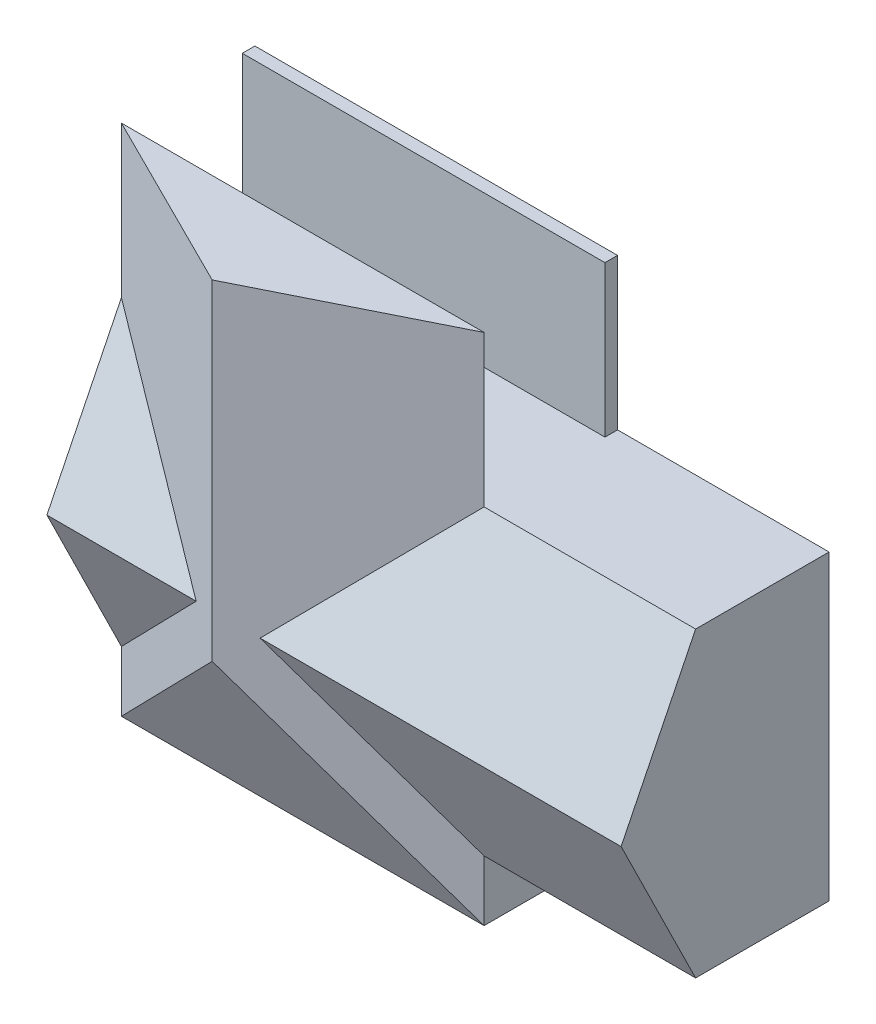
from build123d import *

# Parameters (mm, degrees)
SKETCH3_W           = 11582.4
SKETCH3_H           = 6096
SKETCH3_W_2         = 4341.154286856
SKETCH3_H_2         = 914.4
SKETCH3_W_3         = 1676.4
SKETCH3_H_3         = 2330.801356814
SKETCH3_W_4         = 2663.595025017
SKETCH3_H_4         = 2342.798643186
SKETCH3_W_5         = 1043.645713144
SKETCH3_W_6         = 4013.2
SKETCH3_W_7         = 3708.4
BOSS_EXTRUDE1_DEPTH = 2438.4
SKETCH4_W           = 11582.4
SKETCH4_H           = 6096
BOSS_EXTRUDE2_DEPTH = 254
SKETCH5_W           = 3178.404974983
SKETCH5_H           = 101.6
BOSS_EXTRUDE3_DEPTH = 1016
BOSS_EXTRUDE4_DEPTH = 11582.4
SKETCH8_W           = 7315.2
SKETCH8_H           = 3048
BOSS_EXTRUDE6_DEPTH = 254
BOSS_EXTRUDE7_DEPTH = 10363.2
SKETCH12_W          = 7315.2
SKETCH12_H          = 1219.2
BOSS_EXTRUDE8_DEPTH = 2692.4
BOSS_EXTRUDE9_DEPTH = 1219.2
SKETCH16_W          = 8139.69628299
SKETCH16_H          = 5480.280814736
CUT_EXTRUDE3_DEPTH  = 2099.564


with BuildPart() as part:
    # Sketch3 → Boss-Extrude1 (new body)
    with BuildSketch(Plane.XY):
        with Locations((5791.2, 3048)):
            Rectangle(SKETCH3_W, SKETCH3_H)
        Polygon((152.4, 152.4), (4550.004974983, 152.4), (4550.004974983, 2596.798643186), (5842, 2596.798643186), (5842, 3511.198643186), (5842, 5943.6), (152.4, 5943.6), align=None, mode=Mode.SUBTRACT)
        with Locations((8114.177143428, 3053.998643186)):
            Rectangle(SKETCH3_W_2, SKETCH3_H_2, mode=Mode.SUBTRACT)
        with Locations((6781.8, 4778.199321593)):
            Rectangle(SKETCH3_W_3, SKETCH3_H_3, mode=Mode.SUBTRACT)
        with Locations((5983.402487492, 1323.799321593)):
            Rectangle(SKETCH3_W_4, SKETCH3_H_4, mode=Mode.SUBTRACT)
        with Locations((10908.177143428, 3053.998643186)):
            Rectangle(SKETCH3_W_5, SKETCH3_H_2, mode=Mode.SUBTRACT)
        with Locations((9423.4, 1323.799321593)):
            Rectangle(SKETCH3_W_6, SKETCH3_H_4, mode=Mode.SUBTRACT)
        with Locations((9575.8, 4778.199321593)):
            Rectangle(SKETCH3_W_7, SKETCH3_H_3, mode=Mode.SUBTRACT)
    extrude(amount=BOSS_EXTRUDE1_DEPTH)

    # Sketch4 → Boss-Extrude2 (add)
    with BuildSketch(Plane(origin=(0, 0, 0), x_dir=(-1, 0, 0), z_dir=(0, 0, -1))):
        with Locations((-5791.2, 3048)):
            Rectangle(SKETCH4_W, SKETCH4_H)
    extrude(amount=BOSS_EXTRUDE2_DEPTH)

    # Sketch5 → Boss-Extrude3 (add)
    with BuildSketch(Plane.XY):
        with Locations((1741.602487492, 2545.998643186)):
            Rectangle(SKETCH5_W, SKETCH5_H)
    extrude(amount=BOSS_EXTRUDE3_DEPTH)

    # Sketch6 → Boss-Extrude4 (add)
    with BuildSketch(Plane.ZY):
        Polygon((2438.4, 6096), (2438.4, 0), (3941.507258543, 3048), align=None)
    extrude(amount=-BOSS_EXTRUDE4_DEPTH)

    # Sketch10 → Boss-Extrude7 (add)
    with BuildSketch(Plane(origin=(0, 9144, 0), x_dir=(1, 0, 0), z_dir=(0, 1, 0))):
        Polygon((7315.2, -2438.4), (0, -2438.4), (3655.110432816, -4263.253342026), align=None)
    extrude(amount=-BOSS_EXTRUDE7_DEPTH)

    # Sketch12 → Boss-Extrude8 (add)
    with BuildSketch(Plane(origin=(0, 0, -254), x_dir=(-1, 0, 0), z_dir=(0, 0, -1))):
        with Locations((-3657.6, -609.6)):
            Rectangle(SKETCH12_W, SKETCH12_H)
    extrude(amount=-BOSS_EXTRUDE8_DEPTH)

    # Sketch15 → Boss-Extrude9 (add)
    with BuildSketch(Plane.XZ.offset(1219.2)):
        Polygon((2641.6, 2438.4), (4673.6, 2438.4), (3657.6, 3352.8), align=None)
    extrude(amount=BOSS_EXTRUDE9_DEPTH)

    # Sketch16 → Cut-Extrude3 (cut)
    with BuildSketch(Plane(origin=(0, -1205.755425359, 2445.030130489), x_dir=(1, 0, 0), z_dir=(0, -0.44228869, 0.896872742))):
        with Locations((3533.249297689, 1543.555925229)):
            Rectangle(SKETCH16_W, SKETCH16_H)
    extrude(amount=CUT_EXTRUDE3_DEPTH, mode=Mode.SUBTRACT)


with BuildPart() as body_2:
    # Sketch8 → Boss-Extrude6 (new body)
    with BuildSketch(Plane(origin=(0, 0, -254), x_dir=(-1, 0, 0), z_dir=(0, 0, -1))):
        with Locations((-3657.6, 7620)):
            Rectangle(SKETCH8_W, SKETCH8_H)
    extrude(amount=-BOSS_EXTRUDE6_DEPTH)


solid = Compound([part.part, body_2.part])
